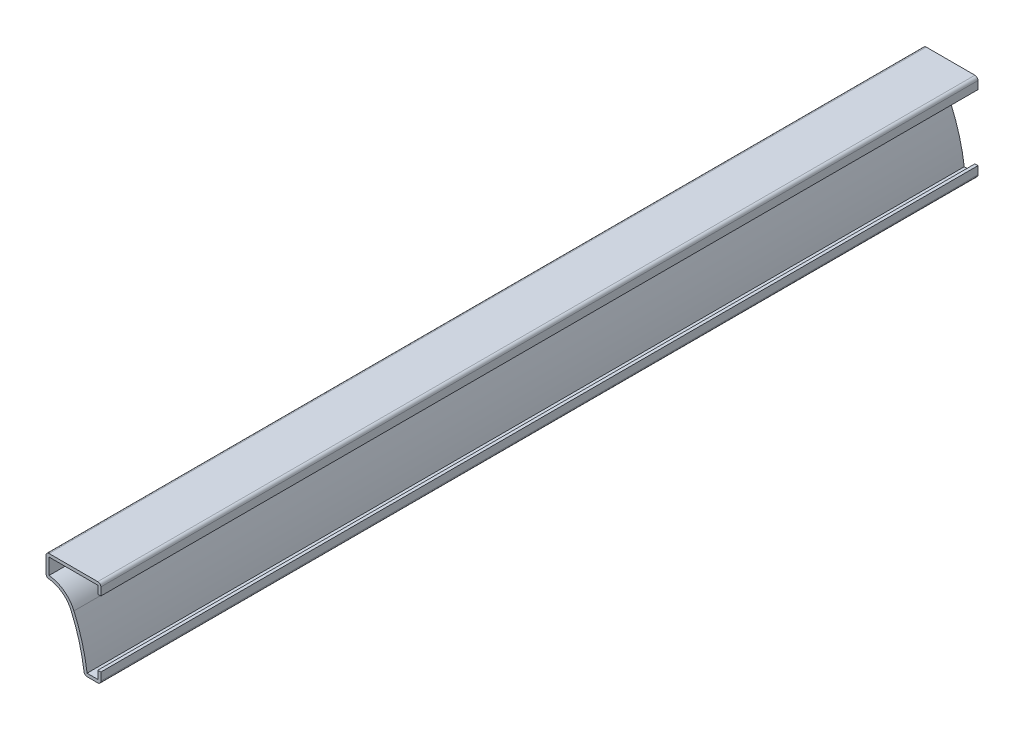
from build123d import *

# Parameters (mm, degrees)
EXTRUDE_THIN1_DEPTH = 254
FILLET1_R           = 0.889


with BuildPart() as part:
    # Sketch1 → Extrude-Thin1 (new body)
    with BuildSketch(Plane.XY):
        with BuildLine():
            Line((0, 3.175), (0, 0))
            Line((0, 0), (-4.7625, 0))
            ThreePointArc((-4.7625, 0), (-6.154789008, 7.270660772), (-8.588987157, 14.261773425))
            ThreePointArc((-8.588987157, 14.261773425), (-11.515725494, 17.745797222), (-15.875, 19.05))
            Line((-15.875, 19.05), (-15.875, 25.4))
            Line((-15.875, 25.4), (0, 25.4))
            Line((0, 25.4), (0, 22.225))
            Line((0, 22.225), (-0.889, 22.225))
            Line((-0.889, 22.225), (-0.889, 24.511))
            Line((-0.889, 24.511), (-14.986, 24.511))
            Line((-14.986, 24.511), (-14.986, 19.894116096))
            ThreePointArc((-14.986, 19.894116096), (-10.661715447, 18.234912963), (-7.772953719, 14.614492048))
            ThreePointArc((-7.772953719, 14.614492048), (-5.400232677, 7.883084139), (-3.977402872, 0.889))
            Line((-3.977402872, 0.889), (-0.889, 0.889))
            Line((-0.889, 0.889), (-0.889, 3.175))
            Line((-0.889, 3.175), (0, 3.175))
        make_face()
    extrude(amount=-EXTRUDE_THIN1_DEPTH)

    # Fillet1
    fillet1_edges = [part.edges().sort_by_distance(p)[0] for p in [
        (0, 0, -127),
        (-4.7625, 0, -127),
        (-15.875, 19.05, -127),
        (-15.875, 25.4, -127),
        (0, 25.4, -127),
    ]]
    fillet(fillet1_edges, radius=FILLET1_R)


solid = part.part
